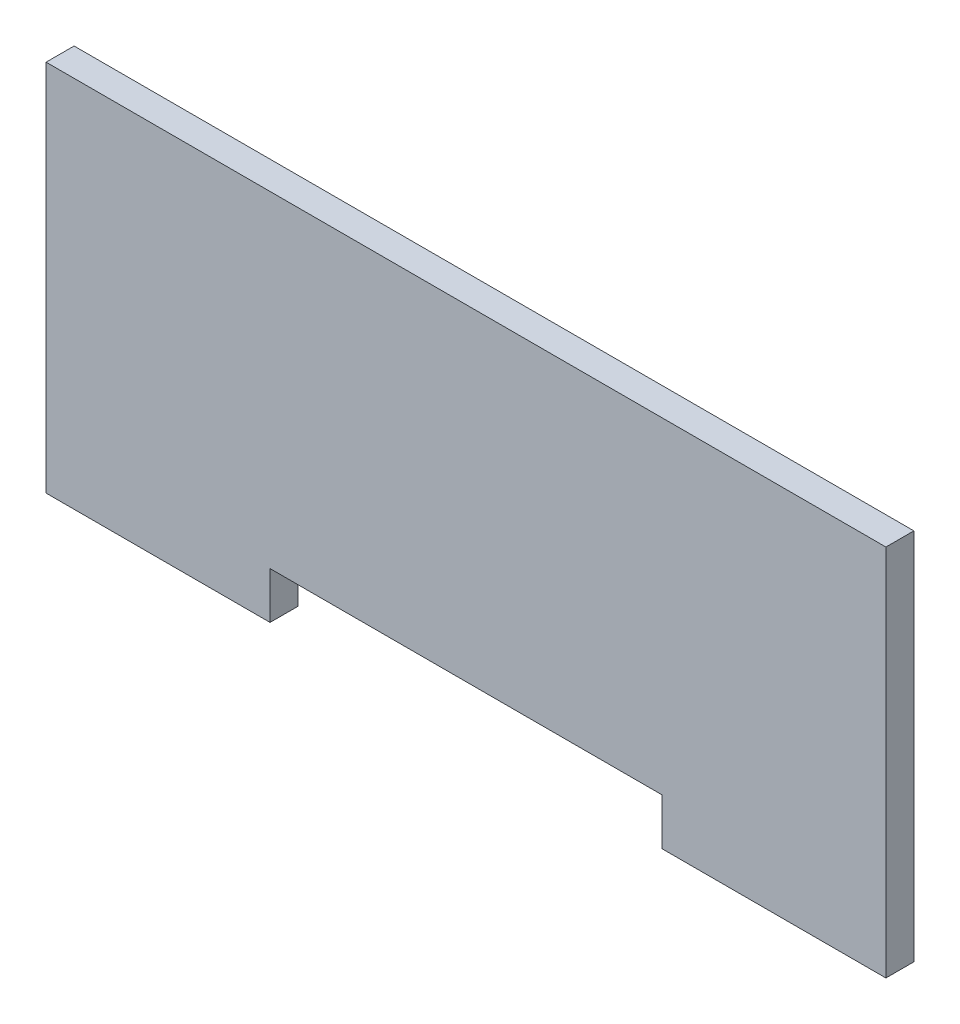
from build123d import *

# Parameters (mm, degrees)
EXTRUDE_1_DEPTH = 3


with BuildPart() as part:
    # 草图1 → 凸台-拉伸1 (new body)
    with BuildSketch(Plane.XY):
        Polygon((-22.694820717, 30.565946334), (67.305179283, 30.565946334), (67.305179283, -9.434053666), (43.305179283, -9.434053666), (43.305179283, -4.434053666), (1.305179283, -4.434053666), (1.305179283, -9.434053666), (-22.694820717, -9.434053666), align=None)
    extrude(amount=EXTRUDE_1_DEPTH)


solid = part.part
